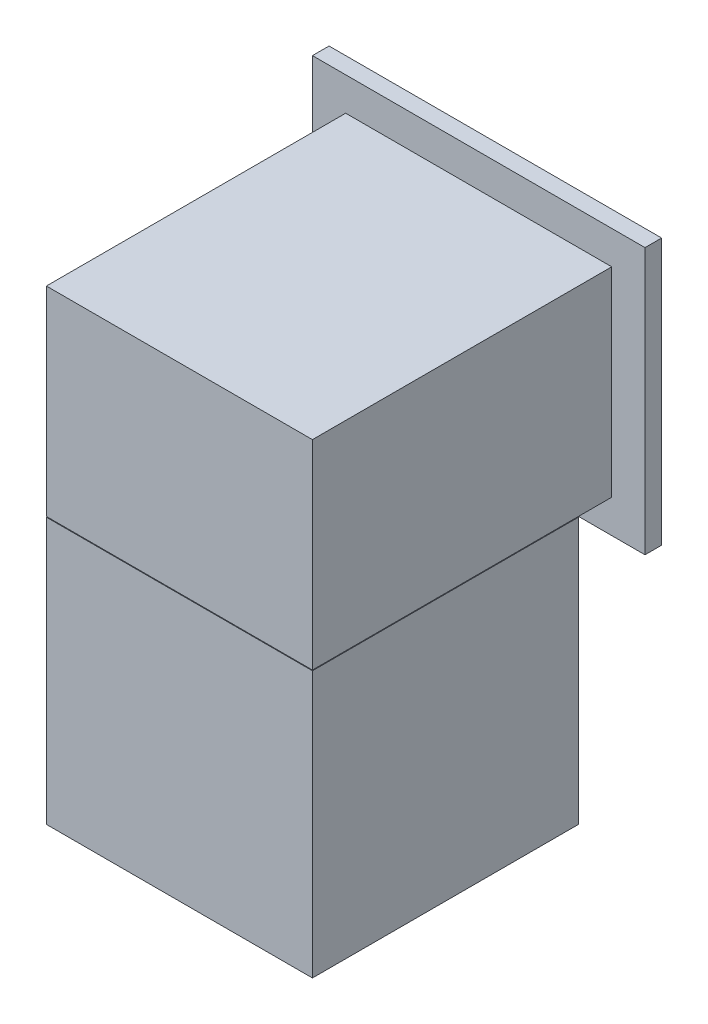
from build123d import *

# Parameters (mm, degrees)
BOSS_EXTRUDE1_DEPTH   = 1000
SKETCH2_W             = 800
SKETCH2_H             = 800
BOSS_EXTRUDE1_2_DEPTH = 1000
SKETCH3_W             = 322.973978715
SKETCH3_H             = 1016.522363687
SKETCH3_W_2           = 410.438471969
CUT_EXTRUDE1_DEPTH    = 2189
SKETCH4_W             = 800
SKETCH4_H             = 600
CUT_EXTRUDE2_DEPTH    = 10
SKETCH5_W             = 590
SKETCH5_H             = 540
CUT_EXTRUDE3_DEPTH    = 200
CUT_EXTRUDE3_TAPER    = 15
SKETCH6_R             = 5
SKETCH6_W             = 340
SKETCH6_H             = 270
SKETCH6_W_2           = 200
SKETCH6_H_2           = 40
CUT_EXTRUDE4_DEPTH    = 10


with BuildPart() as part:
    # Sketch2 → Boss-Extrude1 (new body)
    with BuildSketch(Plane(origin=(0, 0, 0), x_dir=(0, 0, -1), z_dir=(1, 0, 0))):
        Polygon((0, 600), (0, 700), (50, 700), (50, -100), (0, -100), (0, 0), (-900, 0), (-900, 600), align=None)
    extrude(amount=BOSS_EXTRUDE1_DEPTH)


with BuildPart() as body_2:
    # Sketch2 → Boss-Extrude1 2 (new body)
    with BuildSketch(Plane(origin=(0, 0, 0), x_dir=(0, 0, -1), z_dir=(1, 0, 0))):
        with Locations((-500, -402)):
            Rectangle(SKETCH2_W, SKETCH2_H)
    extrude(amount=BOSS_EXTRUDE1_2_DEPTH)


with BuildPart() as cut_extrude1_tool:
    # Sketch3 → Cut-Extrude1 (new body)
    with BuildSketch(Plane(origin=(0, 600, 0), x_dir=(1, 0, 0), z_dir=(0, 1, 0))):
        with Locations((-61.486989358, -508.261181844)):
            Rectangle(SKETCH3_W, SKETCH3_H)
        with Locations((1105.219235985, -508.261181844)):
            Rectangle(SKETCH3_W_2, SKETCH3_H)
    extrude(amount=-CUT_EXTRUDE1_DEPTH)


with BuildPart() as part_1:
    add(part.part)

    # Cut-Extrude1: cut by cut_extrude1_tool
    add(cut_extrude1_tool.part, mode=Mode.SUBTRACT)

    # Sketch4 → Cut-Extrude2 (cut)
    with BuildSketch(Plane(origin=(0, 0, -50), x_dir=(-1, 0, 0), z_dir=(0, 0, -1))):
        with Locations((-500, 300)):
            Rectangle(SKETCH4_W, SKETCH4_H)
    extrude(amount=-CUT_EXTRUDE2_DEPTH, mode=Mode.SUBTRACT)

    # Sketch5 → Cut-Extrude3 (cut)
    with BuildSketch(Plane(origin=(0, 0, -40), x_dir=(-1, 0, 0), z_dir=(0, 0, -1))):
        with Locations((-575, 300)):
            Rectangle(SKETCH5_W, SKETCH5_H)
    extrude(amount=-CUT_EXTRUDE3_DEPTH, taper=CUT_EXTRUDE3_TAPER, mode=Mode.SUBTRACT)

    # Sketch6 → Cut-Extrude4 (cut)
    with BuildSketch(Plane(origin=(0, 0, 160), x_dir=(-1, 0, 0), z_dir=(0, 0, -1))):
        with Locations((-575, 496.410161514)):
            Circle(SKETCH6_R)
        with Locations((-575, 341.410161514)):
            Rectangle(SKETCH6_W, SKETCH6_H)
        with Locations((-683.589838486, 115)):
            Rectangle(SKETCH6_W_2, SKETCH6_H_2)
        with Locations((-463.589838486, 115)):
            Rectangle(SKETCH6_W_2, SKETCH6_H_2)
    extrude(amount=-CUT_EXTRUDE4_DEPTH, mode=Mode.SUBTRACT)


with BuildPart() as body_2_1:
    add(body_2.part)

    # Cut-Extrude1: cut by cut_extrude1_tool
    add(cut_extrude1_tool.part, mode=Mode.SUBTRACT)


solid = Compound([part_1.part, body_2_1.part])
